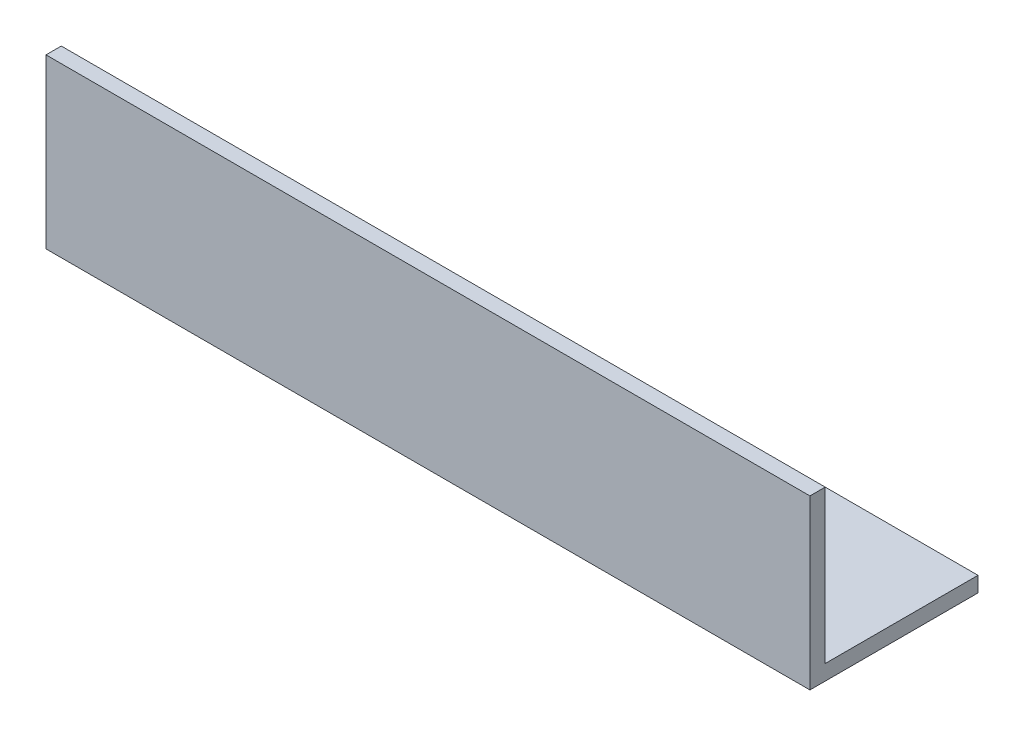
from build123d import *

# Parameters (mm, degrees)
EXTRUDE_1_DEPTH = 150


with BuildPart() as part:
    # Эскиз1 → Вытянуть-Тонкостенный1 (new body)
    with BuildSketch(Plane(origin=(0, 0, 0), x_dir=(0, 0, -1), z_dir=(1, 0, 0))):
        Polygon((0, 30), (0, 0), (30, 0), (30, -3), (-3, -3), (-3, 30), align=None)
    extrude(amount=EXTRUDE_1_DEPTH)


solid = part.part
